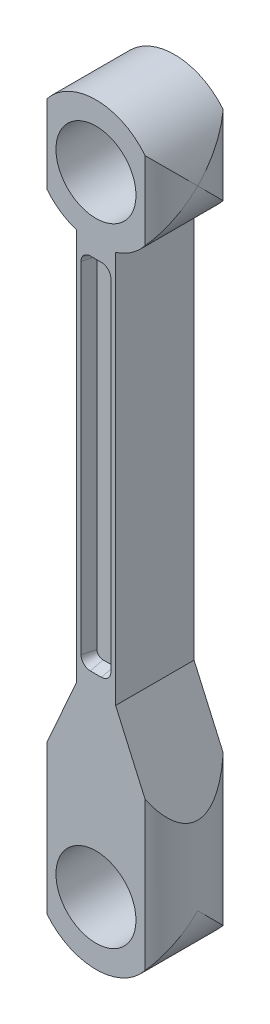
from build123d import *

# Parameters (mm, degrees)
SKETCH1_R               = 6.477
BOSS_EXTRUDE2_DEPTH     = 12.7
CUT_EXTRUDE1_DEPTH      = 2.032
CUT_EXTRUDE1_TAPER      = 15
CUT_EXTRUDE2_DEPTH      = 2.032
CUT_EXTRUDE2_TAPER      = 15
SKETCH6_R               = 15.308441
SKETCH6_R_2             = 10.16
CUT_EXTRUDE3_DEPTH      = 112.76
CUT_EXTRUDE3_DEPTH_BACK = 11.16


with BuildPart() as part:
    # Sketch1 → Boss-Extrude2 (new body)
    with BuildSketch(Plane.XY):
        with BuildLine():
            Line((-10.16, 0), (-10.16, 12.7))
            Line((-10.16, 12.7), (-3.181447, 28.448))
            Line((-3.181447, 28.448), (-3.181447, 91.950959))
            ThreePointArc((-3.181447, 91.950959), (0, 111.76), (3.181447, 91.950959))
            Line((3.181447, 91.950959), (3.181447, 28.448))
            Line((3.181447, 28.448), (10.16, 12.7))
            Line((10.16, 12.7), (10.16, 0))
            ThreePointArc((10.16, 0), (0, -10.16), (-10.16, 0))
        make_face()
        Circle(SKETCH1_R, mode=Mode.SUBTRACT)
        with Locations((0, 101.6)):
            Circle(SKETCH1_R, mode=Mode.SUBTRACT)
    extrude(amount=BOSS_EXTRUDE2_DEPTH)

    # Sketch3 → Cut-Extrude1 (cut)
    with BuildSketch(Plane.XY.offset(12.7)):
        with BuildLine():
            ThreePointArc((-0.895447, 89.408), (-1.973078, 88.961631), (-2.419447, 87.884))
            Line((-2.419447, 87.884), (-2.419447, 32.766))
            ThreePointArc((-2.419447, 32.766), (-1.973078, 31.688369), (-0.895447, 31.242))
            Line((-0.895447, 31.242), (0.895447, 31.242))
            ThreePointArc((0.895447, 31.242), (1.973078, 31.688369), (2.419447, 32.766))
            Line((2.419447, 32.766), (2.419447, 87.884))
            ThreePointArc((2.419447, 87.884), (1.973078, 88.961631), (0.895447, 89.408))
            Line((0.895447, 89.408), (-0.895447, 89.408))
        make_face()
    extrude(amount=-CUT_EXTRUDE1_DEPTH, taper=CUT_EXTRUDE1_TAPER, mode=Mode.SUBTRACT)

    # Sketch5 → Cut-Extrude2 (cut)
    with BuildSketch(Plane(origin=(0, 0, 0), x_dir=(-1, 0, 0), z_dir=(0, 0, -1))):
        with BuildLine():
            ThreePointArc((-0.895447, 89.408), (-1.973078, 88.961631), (-2.419447, 87.884))
            Line((-2.419447, 87.884), (-2.419447, 32.766))
            ThreePointArc((-2.419447, 32.766), (-1.973078, 31.688369), (-0.895447, 31.242))
            Line((-0.895447, 31.242), (0.895447, 31.242))
            ThreePointArc((0.895447, 31.242), (1.973078, 31.688369), (2.419447, 32.766))
            Line((2.419447, 32.766), (2.419447, 87.884))
            ThreePointArc((2.419447, 87.884), (1.973078, 88.961631), (0.895447, 89.408))
            Line((0.895447, 89.408), (-0.895447, 89.408))
        make_face()
    extrude(amount=-CUT_EXTRUDE2_DEPTH, taper=CUT_EXTRUDE2_TAPER, mode=Mode.SUBTRACT)

    # Sketch6 → Cut-Extrude3 (cut, two sides)
    with BuildSketch(Plane(origin=(0, 0, 0), x_dir=(1, 0, 0), z_dir=(0, 1, 0))) as cut_extrude3_sk:
        with Locations((0, -6.388373)):
            Circle(SKETCH6_R)
        with Locations((0, -6.388373)):
            Circle(SKETCH6_R_2, mode=Mode.SUBTRACT)
    extrude(amount=CUT_EXTRUDE3_DEPTH, mode=Mode.SUBTRACT)
    extrude(cut_extrude3_sk.sketch, amount=-CUT_EXTRUDE3_DEPTH_BACK, mode=Mode.SUBTRACT)


solid = part.part
